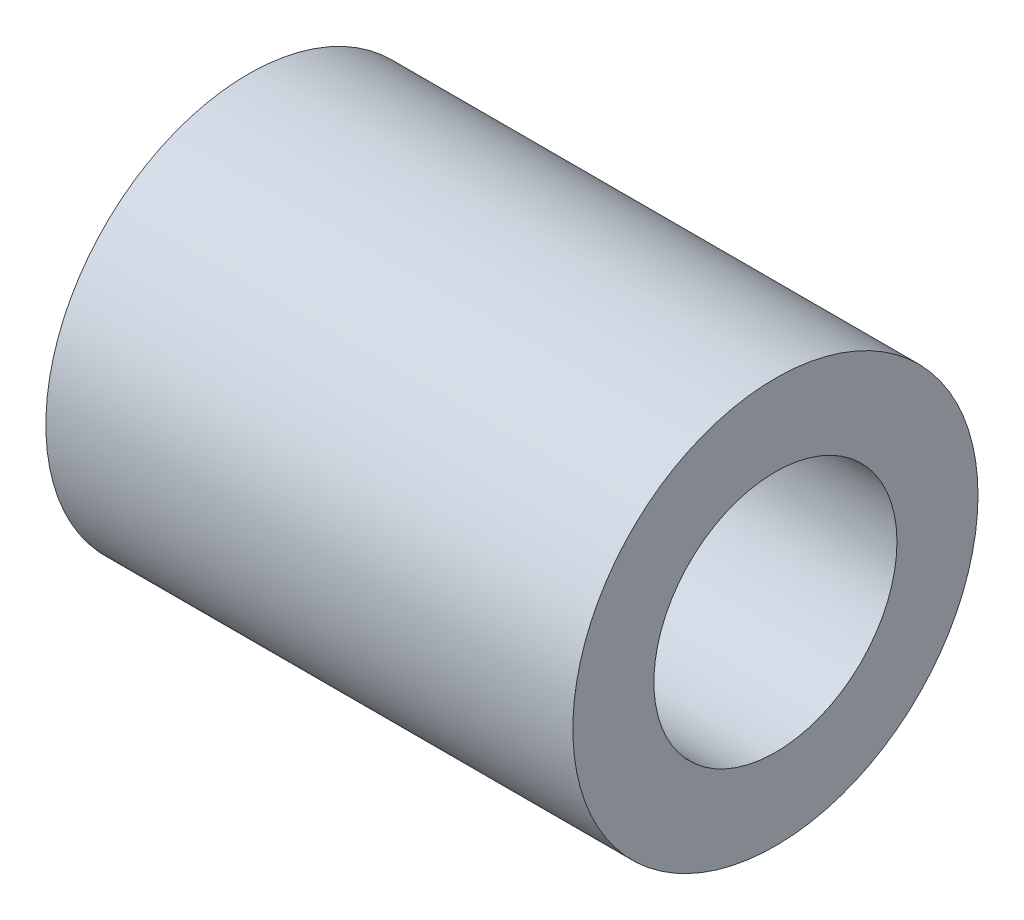
from build123d import *

# Parameters (mm, degrees)
SKETCH1_R           = 7.9375
SKETCH1_R_2         = 4.7625
BOSS_EXTRUDE1_DEPTH = 20.6502


with BuildPart() as part:
    # Sketch1 → Boss-Extrude1 (new body)
    with BuildSketch(Plane(origin=(0, 0, 0), x_dir=(0, 0, -1), z_dir=(1, 0, 0))):
        Circle(SKETCH1_R)
        Circle(SKETCH1_R_2, mode=Mode.SUBTRACT)
    extrude(amount=BOSS_EXTRUDE1_DEPTH)


solid = part.part
